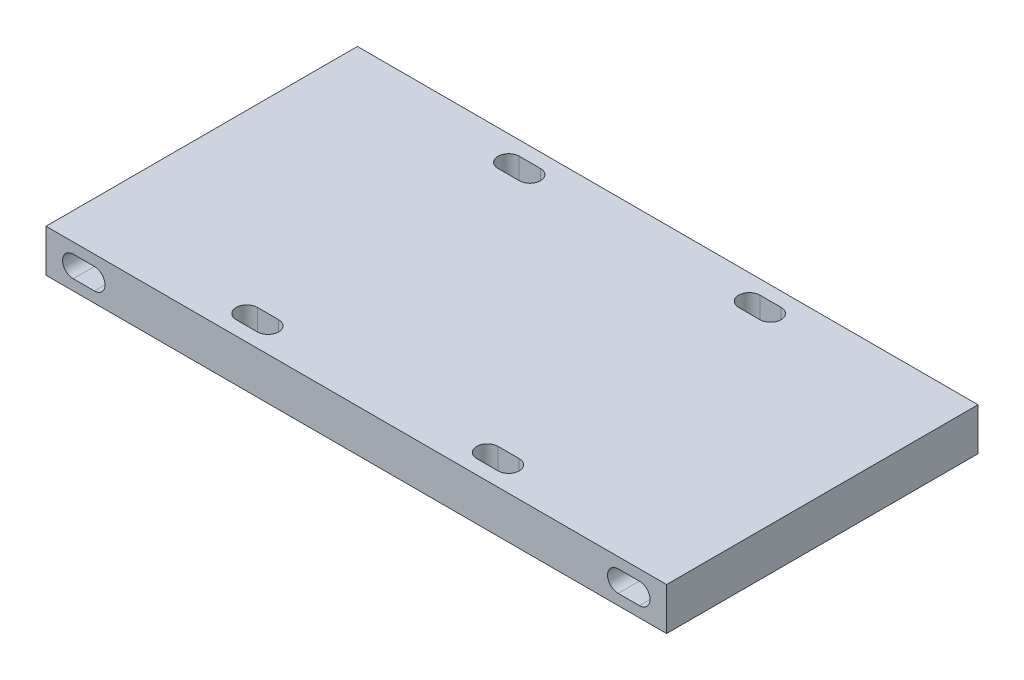
from build123d import *

# Parameters (mm, degrees)
SKETCH_1_W               = 87.68124
SKETCH_1_H               = 6
EXTRUDE_1_DEPTH          = 44
CUT_EXTRUDE_1_DEPTH      = 1
CUT_EXTRUDE_1_DEPTH_BACK = 1
CUT_EXTRUDE_1_2_DEPTH    = 44


with BuildPart() as part:
    # 草图1 → 凸台-拉伸1 (new body)
    with BuildSketch(Plane.XY):
        Rectangle(SKETCH_1_W, SKETCH_1_H)
        with BuildLine():
            Line((-40, 1.5), (-37, 1.5))
            ThreePointArc((-37, 1.5), (-35.5, 0), (-37, -1.5))
            Line((-37, -1.5), (-40, -1.5))
            ThreePointArc((-40, -1.5), (-41.5, 0), (-40, 1.5))
        make_face(mode=Mode.SUBTRACT)
        with BuildLine():
            Line((40, 1.5), (37, 1.5))
            ThreePointArc((37, 1.5), (35.5, 0), (37, -1.5))
            Line((37, -1.5), (40, -1.5))
            ThreePointArc((40, -1.5), (41.5, 0), (40, 1.5))
        make_face(mode=Mode.SUBTRACT)
    extrude(amount=EXTRUDE_1_DEPTH)

    # 草图2 → Cut-Extrude 1 (cut, two sides)
    with BuildSketch(Plane(origin=(0, -3, 0), x_dir=(-1, 0, 0), z_dir=(0, -1, 0))) as cut_extrude_1_sk:
        with BuildLine():
            Line((3.009641995, -23.462761216), (9.016320028, -13.058889678))
            ThreePointArc((9.016320028, -13.058889678), (9.016320028, -10.658889678), (6.937859059, -9.458889678))
            Line((6.937859059, -9.458889678), (5.438821813, -9.458889678))
            ThreePointArc((5.438821813, -9.458889678), (4.238821813, -9.780428709), (3.360360844, -10.658889678))
            Line((3.360360844, -10.658889678), (-2.321304295, -20.499822371))
            ThreePointArc((-2.321304295, -20.499822371), (-2.633710601, -21.490648588), (-2.498105616, -22.520670715))
            Line((-2.498105616, -22.520670715), (-1.114919938, -26.320942131))
            ThreePointArc((-1.114919938, -26.320942131), (-1.092319107, -26.492612485), (-1.144386825, -26.657750188))
            Line((-1.144386825, -26.657750188), (-1.93306975, -28.023789086))
            ThreePointArc((-1.93306975, -28.023789086), (-2.314342209, -28.222266966), (-2.65535696, -27.960597144))
            Line((-2.65535696, -27.960597144), (-6.91393735, -16.260243683))
            ThreePointArc((-6.91393735, -16.260243683), (-6.86572112, -15.894005051), (-6.538060302, -15.723435626))
            Line((-6.538060302, -15.723435626), (-3.866358933, -15.723435626))
            ThreePointArc((-3.866358933, -15.723435626), (-1.900394027, -14.700019073), (-1.611096643, -12.502587282))
            Line((-1.611096643, -12.502587282), (-2.144147775, -11.038041334))
            ThreePointArc((-2.144147775, -11.038041334), (-3.022826617, -9.892924772), (-4.399410065, -9.458889678))
            Line((-4.399410065, -9.458889678), (-12.506390341, -9.458889678))
            ThreePointArc((-12.506390341, -9.458889678), (-14.472355248, -10.482306231), (-14.761652631, -12.679738022))
            Line((-14.761652631, -12.679738022), (-7.924054064, -31.46588569))
            Line((-7.924054064, -31.46588569), (-6.044668822, -30.781845403))
            Line((-6.044668822, -30.781845403), (-12.88226739, -11.995697736))
            ThreePointArc((-12.88226739, -11.995697736), (-12.834051159, -11.629459104), (-12.506390341, -11.458889678))
            Line((-12.506390341, -11.458889678), (-4.399410065, -11.458889678))
            ThreePointArc((-4.399410065, -11.458889678), (-4.16997949, -11.531228861), (-4.023533016, -11.722081621))
            Line((-4.023533016, -11.722081621), (-3.490481885, -13.186627568))
            ThreePointArc((-3.490481885, -13.186627568), (-3.538698115, -13.5528662), (-3.866358933, -13.723435626))
            Line((-3.866358933, -13.723435626), (-6.538060302, -13.723435626))
            ThreePointArc((-6.538060302, -13.723435626), (-8.504025208, -14.746852178), (-8.793322592, -16.94428397))
            Line((-8.793322592, -16.94428397), (-4.534742202, -28.64463743))
            ThreePointArc((-4.534742202, -28.64463743), (-2.488653694, -30.214656362), (-0.201018943, -29.023789086))
            Line((-0.201018943, -29.023789086), (0.587663983, -27.657750188))
            ThreePointArc((0.587663983, -27.657750188), (0.900070289, -26.666923971), (0.764465304, -25.636901844))
            Line((0.764465304, -25.636901844), (-0.618720374, -21.836630428))
            ThreePointArc((-0.618720374, -21.836630428), (-0.641321205, -21.664960074), (-0.589253487, -21.499822371))
            Line((-0.589253487, -21.499822371), (5.092411652, -11.658889678))
            ThreePointArc((5.092411652, -11.658889678), (5.238821813, -11.512479517), (5.438821813, -11.458889678))
            Line((5.438821813, -11.458889678), (6.937859059, -11.458889678))
            ThreePointArc((6.937859059, -11.458889678), (7.28426922, -11.658889678), (7.28426922, -12.058889678))
            Line((7.28426922, -12.058889678), (1.277591188, -22.462761216))
            Line((1.277591188, -22.462761216), (3.009641995, -23.462761216))
        make_face()
    extrude(amount=CUT_EXTRUDE_1_DEPTH, mode=Mode.SUBTRACT)
    extrude(cut_extrude_1_sk.sketch, amount=-CUT_EXTRUDE_1_DEPTH_BACK, mode=Mode.SUBTRACT)

    # 草图3 → Cut-Extrude 1 2 (cut)
    with BuildSketch(Plane.XZ.offset(3)):
        with BuildLine():
            Line((-18.97606525, 39), (-18.97606525, 40.5))
            Line((-18.97606525, 40.5), (-14.47606525, 40.5))
            ThreePointArc((-14.47606525, 40.5), (-14.915405078, 41.560660172), (-15.97606525, 42))
            Line((-15.97606525, 42), (-18.97606525, 42))
            ThreePointArc((-18.97606525, 42), (-20.47606525, 40.5), (-18.97606525, 39))
        make_face()
        with BuildLine():
            ThreePointArc((15.02393475, 42), (13.963274579, 41.560660172), (13.52393475, 40.5))
            Line((13.52393475, 40.5), (18.02393475, 40.5))
            Line((18.02393475, 40.5), (18.02393475, 39))
            ThreePointArc((18.02393475, 39), (19.52393475, 40.5), (18.02393475, 42))
            Line((18.02393475, 42), (15.02393475, 42))
        make_face()
        with BuildLine():
            ThreePointArc((18.02393475, 2), (19.52393475, 3.5), (18.02393475, 5))
            Line((18.02393475, 5), (18.02393475, 3.5))
            Line((18.02393475, 3.5), (13.52393475, 3.5))
            ThreePointArc((13.52393475, 3.5), (13.963274579, 2.439339828), (15.02393475, 2))
            Line((15.02393475, 2), (18.02393475, 2))
        make_face()
        with BuildLine():
            Line((-18.97606525, 3.5), (-18.97606525, 5))
            ThreePointArc((-18.97606525, 5), (-20.47606525, 3.5), (-18.97606525, 2))
            Line((-18.97606525, 2), (-15.97606525, 2))
            ThreePointArc((-15.97606525, 2), (-14.915405078, 2.439339828), (-14.47606525, 3.5))
            Line((-14.47606525, 3.5), (-18.97606525, 3.5))
        make_face()
        with BuildLine():
            Line((-15.97606525, 5), (-18.97606525, 5))
            Line((-18.97606525, 5), (-18.97606525, 3.5))
            Line((-18.97606525, 3.5), (-14.47606525, 3.5))
            ThreePointArc((-14.47606525, 3.5), (-14.915405078, 4.560660172), (-15.97606525, 5))
        make_face()
        with BuildLine():
            Line((-14.47606525, 40.5), (-18.97606525, 40.5))
            Line((-18.97606525, 40.5), (-18.97606525, 39))
            Line((-18.97606525, 39), (-15.97606525, 39))
            ThreePointArc((-15.97606525, 39), (-14.915405078, 39.439339828), (-14.47606525, 40.5))
        make_face()
        with BuildLine():
            Line((18.02393475, 40.5), (13.52393475, 40.5))
            ThreePointArc((13.52393475, 40.5), (13.963274579, 39.439339828), (15.02393475, 39))
            Line((15.02393475, 39), (18.02393475, 39))
            Line((18.02393475, 39), (18.02393475, 40.5))
        make_face()
        with BuildLine():
            Line((18.02393475, 3.5), (18.02393475, 5))
            Line((18.02393475, 5), (15.02393475, 5))
            ThreePointArc((15.02393475, 5), (13.963274579, 4.560660172), (13.52393475, 3.5))
            Line((13.52393475, 3.5), (18.02393475, 3.5))
        make_face()
    extrude(amount=-CUT_EXTRUDE_1_2_DEPTH, mode=Mode.SUBTRACT)


solid = part.part
